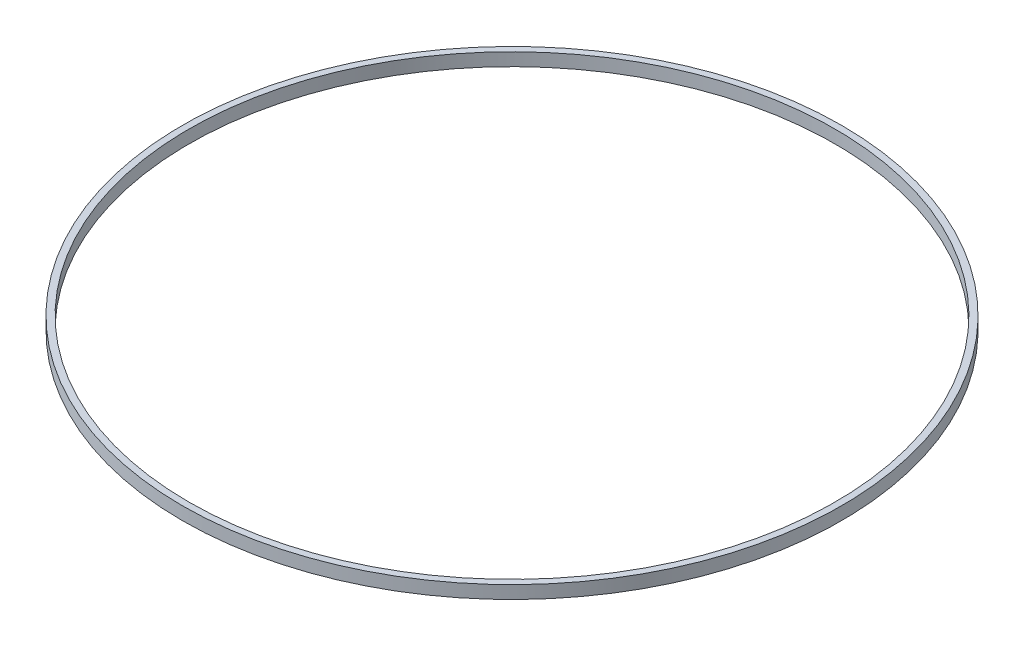
from build123d import *

# Parameters (mm, degrees)
SKETCH1_R           = 51
SKETCH1_R_2         = 50
BOSS_EXTRUDE1_DEPTH = 2


with BuildPart() as part:
    # Sketch1 → Boss-Extrude1 (new body)
    with BuildSketch(Plane(origin=(0, 0, 0), x_dir=(1, 0, 0), z_dir=(0, 1, 0))):
        Circle(SKETCH1_R)
        Circle(SKETCH1_R_2, mode=Mode.SUBTRACT)
    extrude(amount=BOSS_EXTRUDE1_DEPTH)


solid = part.part
